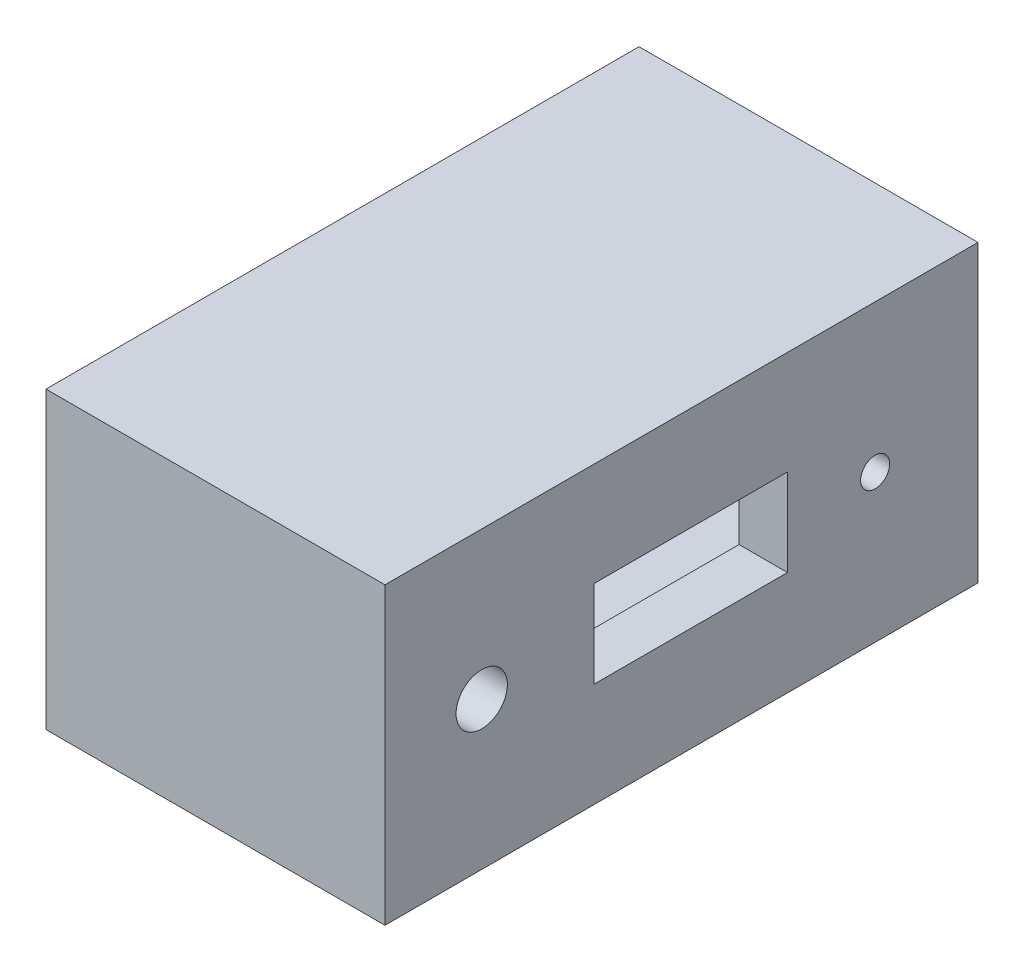
from build123d import *

# Parameters (mm, degrees)
SKETCH3_W               = 6.123251055
SKETCH3_H               = 3.044978856
BOSS_EXTRUDE1_DEPTH     = 3.5
SKETCH4_W               = 5.882824508
SKETCH4_H               = 2.759961498
CUT_EXTRUDE1_DEPTH      = 3
CUT_EXTRUDE1_DEPTH_BACK = 3.5
SKETCH5_W               = 2
SKETCH5_H               = 0.9
SKETCH5_R               = 0.265
SKETCH5_R_2             = 0.15
CUT_EXTRUDE4_DEPTH      = 19
CUT_EXTRUDE4_DEPTH_BACK = 9.5


with BuildPart() as part:
    # Sketch3 → Boss-Extrude1 (new body)
    with BuildSketch(Plane(origin=(0, 0, 0), x_dir=(0, 0, -1), z_dir=(1, 0, 0))):
        with Locations((3.061625528, 1.522489428)):
            Rectangle(SKETCH3_W, SKETCH3_H)
    extrude(amount=BOSS_EXTRUDE1_DEPTH)

    # Sketch4 → Cut-Extrude1 (cut, two sides)
    with BuildSketch(Plane(origin=(0, 0, 0), x_dir=(0, 0, -1), z_dir=(1, 0, 0))) as cut_extrude1_sk:
        with Locations((3.052253754, 1.517218169)):
            Rectangle(SKETCH4_W, SKETCH4_H)
    extrude(amount=CUT_EXTRUDE1_DEPTH, mode=Mode.SUBTRACT)
    extrude(cut_extrude1_sk.sketch, amount=-CUT_EXTRUDE1_DEPTH_BACK, mode=Mode.SUBTRACT)

    # Sketch5 → Cut-Extrude4 (cut, two sides)
    with BuildSketch(Plane(origin=(0, 0, 0), x_dir=(0, 0, -1), z_dir=(1, 0, 0))) as cut_extrude4_sk:
        with Locations((3.155962341, 1.526656808)):
            Rectangle(SKETCH5_W, SKETCH5_H)
        with Locations((0.999206787, 1.522489428)):
            Circle(SKETCH5_R)
        with Locations((5.061218107, 1.522489428)):
            Circle(SKETCH5_R_2)
    extrude(amount=CUT_EXTRUDE4_DEPTH, mode=Mode.SUBTRACT)
    extrude(cut_extrude4_sk.sketch, amount=-CUT_EXTRUDE4_DEPTH_BACK, mode=Mode.SUBTRACT)


solid = part.part
